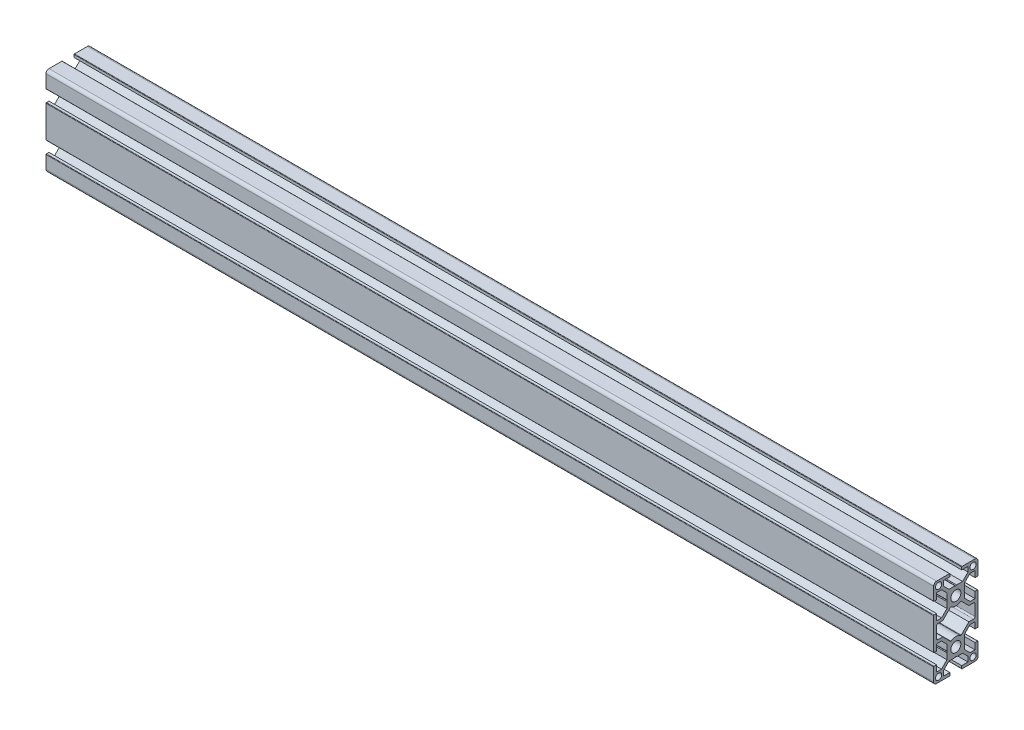
from build123d import *

# Parameters (mm, degrees)
SKETCH_1_R              = 2.1
SKETCH_1_R_2            = 3.4
F_30XS6_30X60S6_1_DEPTH = 600


with BuildPart() as part:
    # 草图1 → 30xs6 30X60S6(1) (new body)
    with BuildSketch(Plane.ZY):
        with BuildLine():
            Line((-13, -30), (-4.3, -30))
            ThreePointArc((-4.3, -30), (-4.087867966, -29.912132034), (-4, -29.7))
            Line((-4, -29.7), (-4, -28))
            Line((-4, -28), (-8.249999995, -28))
            Line((-8.249999995, -28), (-8.249999995, -24.664213567))
            Line((-8.249999995, -24.664213567), (-4.585786428, -21))
            Line((-4.585786428, -21), (-0.519615237, -21))
            Line((-0.519615237, -21), (5e-09, -20.7))
            Line((5e-09, -20.7), (0.519615247, -21))
            Line((0.519615247, -21), (4.585786438, -21))
            Line((4.585786438, -21), (8.250000005, -24.664213567))
            Line((8.250000005, -24.664213567), (8.250000005, -28))
            Line((8.250000005, -28), (4, -28))
            Line((4, -28), (4, -29.7))
            ThreePointArc((4, -29.7), (4.087867966, -29.912132034), (4.3, -30))
            Line((4.3, -30), (13, -30))
            ThreePointArc((13, -30), (14.414213562, -29.414213562), (15, -28))
            Line((15, -28), (15, -19.3000023))
            ThreePointArc((15, -19.3000023), (14.912132034, -19.087870266), (14.7, -19.0000023))
            Line((14.7, -19.0000023), (13.000000005, -19.0000023))
            Line((13.000000005, -19.0000023), (13.000000005, -23.250000005))
            Line((13.000000005, -23.250000005), (9.664213567, -23.250000005))
            Line((9.664213567, -23.250000005), (6.000000005, -19.585786443))
            Line((6.000000005, -19.585786443), (6.000000005, -15.519615247))
            Line((6.000000005, -15.519615247), (5.700000005, -15.000000005))
            Line((5.700000005, -15.000000005), (6.000000005, -14.480384763))
            Line((6.000000005, -14.480384763), (6.000000005, -10.414213567))
            Line((6.000000005, -10.414213567), (9.664213567, -6.750000005))
            Line((9.664213567, -6.750000005), (13.000000005, -6.750000005))
            Line((13.000000005, -6.750000005), (13.000000005, -11.0000023))
            Line((13.000000005, -11.0000023), (14.7, -11.0000023))
            ThreePointArc((14.7, -11.0000023), (14.912132034, -10.912134335), (15, -10.7000023))
            Line((15, -10.7000023), (15, 10.7000023))
            ThreePointArc((15, 10.7000023), (14.912132034, 10.912134335), (14.7, 11.0000023))
            Line((14.7, 11.0000023), (13.000000005, 11.0000023))
            Line((13.000000005, 11.0000023), (13.000000005, 6.749999995))
            Line((13.000000005, 6.749999995), (9.664213567, 6.749999995))
            Line((9.664213567, 6.749999995), (6.000000005, 10.414213557))
            Line((6.000000005, 10.414213557), (6.000000005, 14.480384753))
            Line((6.000000005, 14.480384753), (5.700000005, 14.999999995))
            Line((5.700000005, 14.999999995), (6.000000005, 15.519615237))
            Line((6.000000005, 15.519615237), (6.000000005, 19.585786433))
            Line((6.000000005, 19.585786433), (9.664213567, 23.249999995))
            Line((9.664213567, 23.249999995), (13.000000005, 23.249999995))
            Line((13.000000005, 23.249999995), (13.000000005, 19.0000023))
            Line((13.000000005, 19.0000023), (14.7, 19.0000023))
            ThreePointArc((14.7, 19.0000023), (14.912132034, 19.087870266), (15, 19.3000023))
            Line((15, 19.3000023), (15, 28))
            ThreePointArc((15, 28), (14.414213562, 29.414213562), (13, 30))
            Line((13, 30), (4.3, 30))
            ThreePointArc((4.3, 30), (4.087867966, 29.912132034), (4, 29.7))
            Line((4, 29.7), (4, 28))
            Line((4, 28), (8.250000005, 28))
            Line((8.250000005, 28), (8.250000005, 24.664213557))
            Line((8.250000005, 24.664213557), (4.585786448, 21))
            Line((4.585786448, 21), (0.519615247, 21))
            Line((0.519615247, 21), (5e-09, 20.7))
            Line((5e-09, 20.7), (-0.519615237, 21))
            Line((-0.519615237, 21), (-4.585786438, 21))
            Line((-4.585786438, 21), (-8.249999995, 24.664213557))
            Line((-8.249999995, 24.664213557), (-8.249999995, 28))
            Line((-8.249999995, 28), (-4, 28))
            Line((-4, 28), (-4, 29.7))
            ThreePointArc((-4, 29.7), (-4.087867966, 29.912132034), (-4.3, 30))
            Line((-4.3, 30), (-13, 30))
            ThreePointArc((-13, 30), (-14.414213562, 29.414213562), (-15, 28))
            Line((-15, 28), (-15, 19.3000023))
            ThreePointArc((-15, 19.3000023), (-14.912132034, 19.087870266), (-14.7, 19.0000023))
            Line((-14.7, 19.0000023), (-12.999999995, 19.0000023))
            Line((-12.999999995, 19.0000023), (-12.999999995, 23.249999995))
            Line((-12.999999995, 23.249999995), (-9.664213557, 23.249999995))
            Line((-9.664213557, 23.249999995), (-5.999999995, 19.585786433))
            Line((-5.999999995, 19.585786433), (-5.999999995, 15.519615237))
            Line((-5.999999995, 15.519615237), (-5.699999995, 14.999999995))
            Line((-5.699999995, 14.999999995), (-5.999999995, 14.480384753))
            Line((-5.999999995, 14.480384753), (-5.999999995, 10.414213557))
            Line((-5.999999995, 10.414213557), (-9.664213557, 6.749999995))
            Line((-9.664213557, 6.749999995), (-12.999999995, 6.749999995))
            Line((-12.999999995, 6.749999995), (-12.999999995, 11.0000023))
            Line((-12.999999995, 11.0000023), (-14.7, 11.0000023))
            ThreePointArc((-14.7, 11.0000023), (-14.912132034, 10.912134335), (-15, 10.7000023))
            Line((-15, 10.7000023), (-15, -10.7000023))
            ThreePointArc((-15, -10.7000023), (-14.912132034, -10.912134335), (-14.7, -11.0000023))
            Line((-14.7, -11.0000023), (-12.999999995, -11.0000023))
            Line((-12.999999995, -11.0000023), (-12.999999995, -6.750000005))
            Line((-12.999999995, -6.750000005), (-9.664213557, -6.750000005))
            Line((-9.664213557, -6.750000005), (-5.999999995, -10.414213567))
            Line((-5.999999995, -10.414213567), (-5.999999995, -14.480384763))
            Line((-5.999999995, -14.480384763), (-5.699999995, -15.000000005))
            Line((-5.699999995, -15.000000005), (-5.999999995, -15.519615247))
            Line((-5.999999995, -15.519615247), (-5.999999995, -19.585786443))
            Line((-5.999999995, -19.585786443), (-9.664213557, -23.250000005))
            Line((-9.664213557, -23.250000005), (-12.999999995, -23.250000005))
            Line((-12.999999995, -23.250000005), (-12.999999995, -19.0000023))
            Line((-12.999999995, -19.0000023), (-14.7, -19.0000023))
            ThreePointArc((-14.7, -19.0000023), (-14.912132034, -19.087870266), (-15, -19.3000023))
            Line((-15, -19.3000023), (-15, -28))
            ThreePointArc((-15, -28), (-14.414213562, -29.414213562), (-13, -30))
        make_face()
        with Locations((11.625000005, 26.624999995)):
            Circle(SKETCH_1_R, mode=Mode.SUBTRACT)
        with Locations((11.625000005, -26.625000005)):
            Circle(SKETCH_1_R, mode=Mode.SUBTRACT)
        with Locations((4.55e-07, -15.00000049)):
            Circle(SKETCH_1_R_2, mode=Mode.SUBTRACT)
        with Locations((4.55e-07, 15.0000023)):
            Circle(SKETCH_1_R_2, mode=Mode.SUBTRACT)
        with Locations((-11.624999995, 26.624999995)):
            Circle(SKETCH_1_R, mode=Mode.SUBTRACT)
        with Locations((-11.624999995, -26.625000005)):
            Circle(SKETCH_1_R, mode=Mode.SUBTRACT)
        with BuildLine():
            Line((-12.999999995, 3.749999995), (-12.999999995, -3.750000005))
            ThreePointArc((-12.999999995, -3.750000005), (-12.707106776, -4.457106786), (-11.999999995, -4.750000005))
            Line((-11.999999995, -4.750000005), (-8.835786433, -4.750000005))
            Line((-8.835786433, -4.750000005), (-3.651790591, -9.933995846))
            ThreePointArc((-3.651790591, -9.933995846), (-3.470778838, -10.020245326), (-3.275865231, -9.973203714))
            ThreePointArc((-3.275865231, -9.973203714), (1.45e-07, -9.000002005), (3.275865622, -9.973203376))
            ThreePointArc((3.275865622, -9.973203376), (3.470779219, -10.02024497), (3.651790956, -9.933995491))
            Line((3.651790956, -9.933995491), (8.835786443, -4.750000005))
            Line((8.835786443, -4.750000005), (12.000000005, -4.750000005))
            ThreePointArc((12.000000005, -4.750000005), (12.707106786, -4.457106786), (13.000000005, -3.750000005))
            Line((13.000000005, -3.750000005), (13.000000005, 3.749999995))
            ThreePointArc((13.000000005, 3.749999995), (12.707106786, 4.457106776), (12.000000005, 4.749999995))
            Line((12.000000005, 4.749999995), (8.835786443, 4.749999995))
            Line((8.835786443, 4.749999995), (3.6517913, 9.933995138))
            ThreePointArc((3.6517913, 9.933995138), (3.470779584, 10.020244614), (3.275866001, 9.973203046))
            ThreePointArc((3.275866001, 9.973203046), (1.45e-07, 9.000001815), (-3.27586561, 9.973203384))
            ThreePointArc((-3.27586561, 9.973203384), (-3.470779203, 10.020244971), (-3.651790935, 9.933995493))
            Line((-3.651790935, 9.933995493), (-8.835786433, 4.749999995))
            Line((-8.835786433, 4.749999995), (-11.999999995, 4.749999995))
            ThreePointArc((-11.999999995, 4.749999995), (-12.707106776, 4.457106776), (-12.999999995, 3.749999995))
        make_face(mode=Mode.SUBTRACT)
    extrude(amount=F_30XS6_30X60S6_1_DEPTH)


solid = part.part
